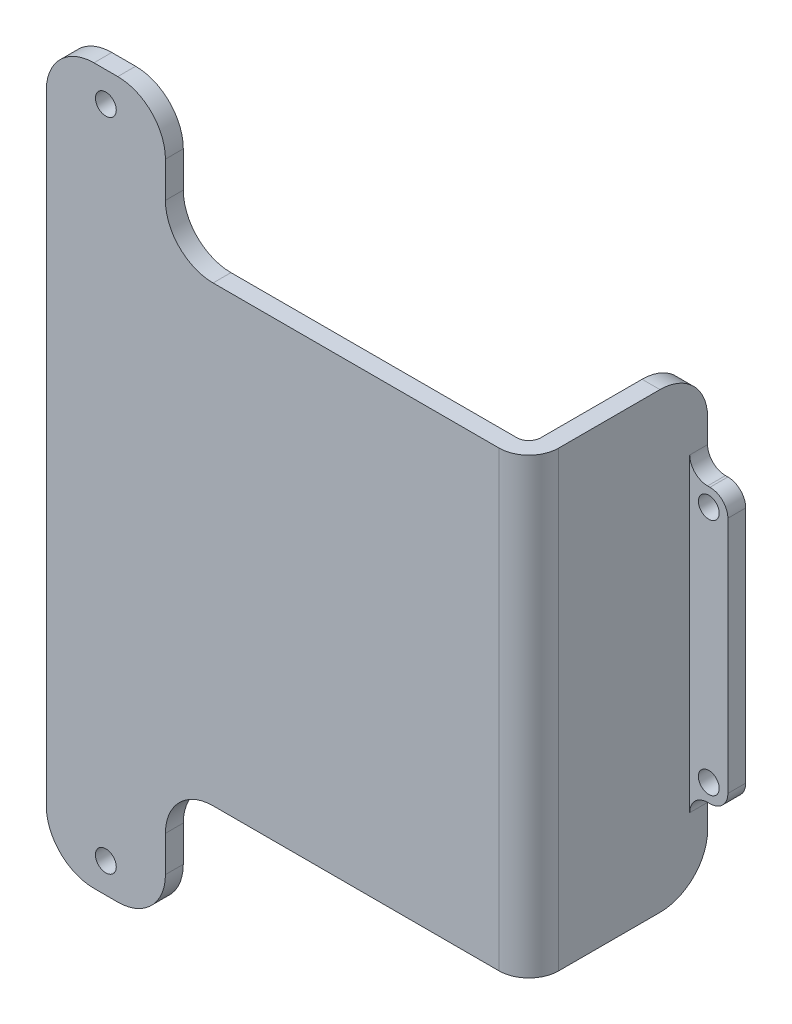
from build123d import *

# Parameters (mm, degrees)
ESQUISSE1_R             = 1.75
BOSS_EXTRU_1_DEPTH      = 3
ESQUISSE1_3_R           = 1.75
BOSS_EXTRU_2_DEPTH      = 27
ESQUISSE1_4_W           = 6.4
ESQUISSE1_4_H           = 46
ESQUISSE1_4_R           = 1.75
ENL_V_MAT_EXTRU_1_DEPTH = 24
CONG_1_R                = 8
CONG_2_R                = 3
CONG_3_R                = 2
CONG_4_R                = 5


with BuildPart() as part:
    # Esquisse1 → Boss.-Extru.1 (new body)
    with BuildSketch(Plane.XY):
        Polygon((30.5, 38), (-30.5, 38), (-30.5, 60), (-50.5, 60), (-50.5, -60), (-30.5, -60), (-30.5, -38), (30.5, -38), align=None)
        with Locations((-40.5, 55)):
            Circle(ESQUISSE1_R, mode=Mode.SUBTRACT)
        with Locations((-40.5, -55)):
            Circle(ESQUISSE1_R, mode=Mode.SUBTRACT)
    extrude(amount=BOSS_EXTRU_1_DEPTH)

    # Esquisse1_3 → Boss.-Extru.2 (add)
    with BuildSketch(Plane.XY):
        Polygon((36.9, -23), (36.9, 23), (30.5, 23), (30.5, 38), (27.5, 38), (27.5, -38), (30.5, -38), (30.5, -23), align=None)
        with Locations((33.7, -20)):
            Circle(ESQUISSE1_3_R, mode=Mode.SUBTRACT)
        with Locations((33.7, 20)):
            Circle(ESQUISSE1_3_R, mode=Mode.SUBTRACT)
    extrude(amount=-BOSS_EXTRU_2_DEPTH)

    # Esquisse1_4 → Enl_v. mat.-Extru.1 (cut)
    with BuildSketch(Plane.XY):
        with Locations((33.7, 0)):
            Rectangle(ESQUISSE1_4_W, ESQUISSE1_4_H)
        with Locations((33.7, -20)):
            Circle(ESQUISSE1_4_R, mode=Mode.SUBTRACT)
        with Locations((33.7, 20)):
            Circle(ESQUISSE1_4_R, mode=Mode.SUBTRACT)
    extrude(amount=-ENL_V_MAT_EXTRU_1_DEPTH, mode=Mode.SUBTRACT)

    # Cong_1
    cong_1_edges = [part.edges().sort_by_distance(p)[0] for p in [
        (-30.5, 38, 1.5),
        (-30.5, 60, 1.5),
        (-50.5, 60, 1.5),
        (-30.5, -38, 1.5),
        (-50.5, -60, 1.5),
        (-30.5, -60, 1.5),
        (29, 38, -27),
        (29, -38, -27),
    ]]
    fillet(cong_1_edges, radius=CONG_1_R)

    # Cong_2
    cong_2_edges = [part.edges().sort_by_distance(p)[0] for p in [
        (30.5, 23, -25.5),
        (36.9, 23, -25.5),
        (36.9, -23, -25.5),
        (30.5, -23, -25.5),
    ]]
    fillet(cong_2_edges, radius=CONG_2_R)

    # Cong_3
    cong_3_edges = [part.edges().sort_by_distance(p)[0] for p in [
        (27.5, 0, 0),
    ]]
    fillet(cong_3_edges, radius=CONG_3_R)

    # Cong_4
    cong_4_edges = [part.edges().sort_by_distance(p)[0] for p in [
        (30.5, 0, 3),
    ]]
    fillet(cong_4_edges, radius=CONG_4_R)


solid = part.part
